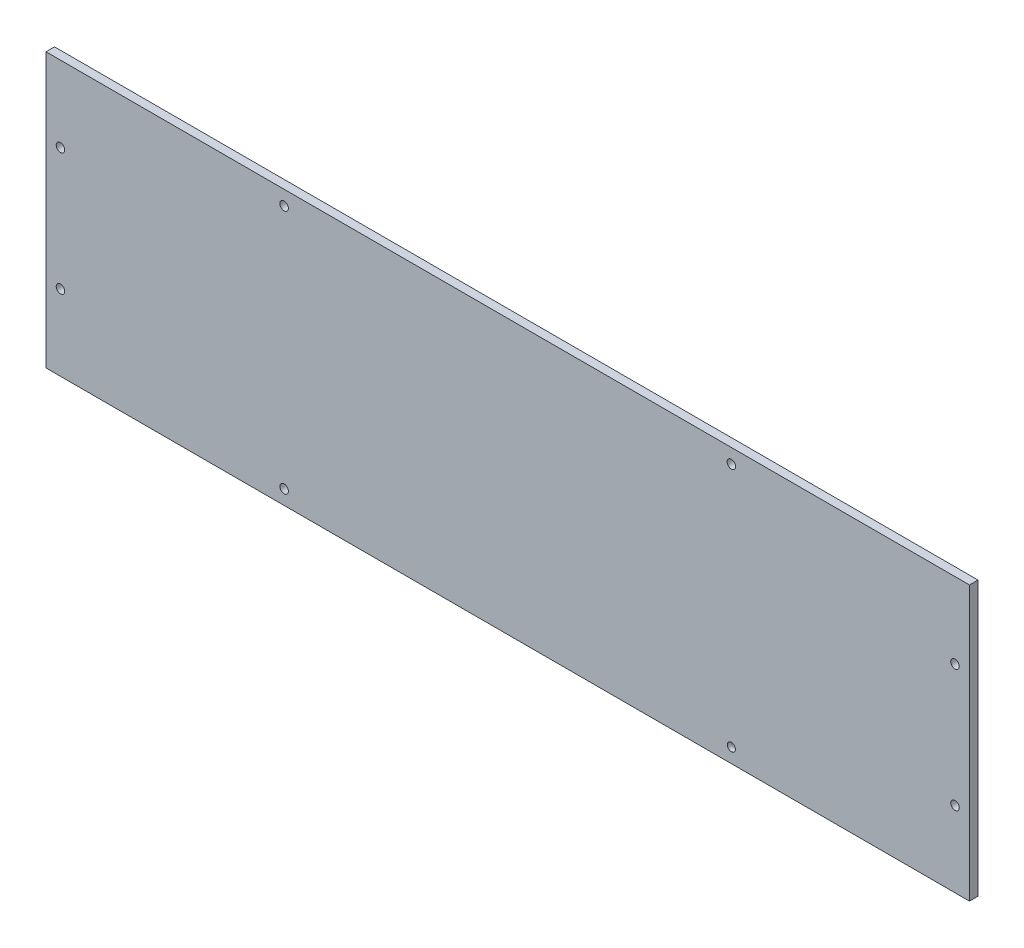
from build123d import *

# Parameters (mm, degrees)
MODEL_W             = 304.8012934
MODEL_H             = 76.2008736
MODEL_W_2           = 13.9995
MODEL_H_2           = 13.9995
MODEL_W_3           = 13.9994
MODEL_W_4           = 13.9992
MODEL_W_5           = 3.302
MODEL_H_3           = 14.2007
MODEL_W_6           = 13.999
MODEL_W_7           = 3.3
MODEL_W_8           = 3.3004
MODEL_H_4           = 14.2005
MODEL_W_9           = 14.0008
MODEL_W_10          = 3.2992
MODEL_W_11          = 13.9991
MODEL_W_12          = 14.001
MODEL_H_5           = 13.9996
BOSS_EXTRUDE2_DEPTH = 1.5
SKETCH3_W           = 324.9887066
SKETCH3_H           = 96.3745066
SKETCH3_W_2         = 304.8012934
SKETCH3_H_2         = 76.2008736
BOSS_EXTRUDE4_DEPTH = 1.5
SKETCH4_R           = 1.5
CUT_EXTRUDE2_DEPTH  = 2.54
BOSS_EXTRUDE5_DEPTH = 1.5
SKETCH6_W           = 324.9887066
SKETCH6_H           = 96.3745066
SKETCH6_R           = 1.5
SKETCH6_R_2         = 1.437968672
BOSS_EXTRUDE6_DEPTH = 1.5


with BuildPart() as part:
    # Model → Boss-Extrude2 (new body)
    with BuildSketch(Plane.XY):
        with Locations((162.4943533, 48.1803632)):
            Rectangle(MODEL_W, MODEL_H)
        with Locations((19.61845, 19.60605)):
            Rectangle(MODEL_W_2, MODEL_H_2, mode=Mode.SUBTRACT)
        with Locations((38.6684, 19.60605)):
            Rectangle(MODEL_W_3, MODEL_H_2, mode=Mode.SUBTRACT)
        with Locations((57.7185, 19.60605)):
            Rectangle(MODEL_W_4, MODEL_H_2, mode=Mode.SUBTRACT)
        with Locations((76.7685, 19.60605)):
            Rectangle(MODEL_W_4, MODEL_H_2, mode=Mode.SUBTRACT)
        with Locations((131.543, 18.95565)):
            Rectangle(MODEL_W_5, MODEL_H_3, mode=Mode.SUBTRACT)
        with Locations((143.4435, 19.60605)):
            Rectangle(MODEL_W_6, MODEL_H_2, mode=Mode.SUBTRACT)
        with Locations((155.344, 18.95565)):
            Rectangle(MODEL_W_7, MODEL_H_3, mode=Mode.SUBTRACT)
        with Locations((17.2427, 38.00555)):
            Rectangle(MODEL_W_8, MODEL_H_4, mode=Mode.SUBTRACT)
        with Locations((29.1427, 38.65605)):
            Rectangle(MODEL_W_9, MODEL_H_2, mode=Mode.SUBTRACT)
        with Locations((41.0436, 38.00555)):
            Rectangle(MODEL_W_10, MODEL_H_4, mode=Mode.SUBTRACT)
        with Locations((57.7185, 38.65605)):
            Rectangle(MODEL_W_4, MODEL_H_2, mode=Mode.SUBTRACT)
        with Locations((76.7685, 38.65605)):
            Rectangle(MODEL_W_4, MODEL_H_2, mode=Mode.SUBTRACT)
        with Locations((95.81845, 38.65605)):
            Rectangle(MODEL_W_11, MODEL_H_2, mode=Mode.SUBTRACT)
        with Locations((114.8675, 38.65605)):
            Rectangle(MODEL_W_12, MODEL_H_2, mode=Mode.SUBTRACT)
        with Locations((133.9185, 38.65605)):
            Rectangle(MODEL_W_6, MODEL_H_2, mode=Mode.SUBTRACT)
        with Locations((152.9685, 38.65605)):
            Rectangle(MODEL_W_6, MODEL_H_2, mode=Mode.SUBTRACT)
        with Locations((169.643, 18.95565)):
            Rectangle(MODEL_W_5, MODEL_H_3, mode=Mode.SUBTRACT)
        with Locations((181.5435, 19.60605)):
            Rectangle(MODEL_W_6, MODEL_H_2, mode=Mode.SUBTRACT)
        with Locations((193.444, 18.95565)):
            Rectangle(MODEL_W_7, MODEL_H_3, mode=Mode.SUBTRACT)
        with Locations((248.2185, 19.60605)):
            Rectangle(MODEL_W_6, MODEL_H_2, mode=Mode.SUBTRACT)
        with Locations((267.2685, 19.60605)):
            Rectangle(MODEL_W_6, MODEL_H_2, mode=Mode.SUBTRACT)
        with Locations((286.3185, 19.60605)):
            Rectangle(MODEL_W_6, MODEL_H_2, mode=Mode.SUBTRACT)
        with Locations((305.3685, 19.60605)):
            Rectangle(MODEL_W_6, MODEL_H_2, mode=Mode.SUBTRACT)
        with Locations((172.0185, 38.65605)):
            Rectangle(MODEL_W_6, MODEL_H_2, mode=Mode.SUBTRACT)
        with Locations((191.0685, 38.65605)):
            Rectangle(MODEL_W_6, MODEL_H_2, mode=Mode.SUBTRACT)
        with Locations((210.1185, 38.65605)):
            Rectangle(MODEL_W_6, MODEL_H_2, mode=Mode.SUBTRACT)
        with Locations((229.1685, 38.65605)):
            Rectangle(MODEL_W_6, MODEL_H_2, mode=Mode.SUBTRACT)
        with Locations((248.2185, 38.65605)):
            Rectangle(MODEL_W_6, MODEL_H_2, mode=Mode.SUBTRACT)
        with Locations((267.2685, 38.65605)):
            Rectangle(MODEL_W_6, MODEL_H_2, mode=Mode.SUBTRACT)
        with Locations((283.944, 38.00555)):
            Rectangle(MODEL_W_7, MODEL_H_4, mode=Mode.SUBTRACT)
        with Locations((295.8435, 38.65605)):
            Rectangle(MODEL_W_6, MODEL_H_2, mode=Mode.SUBTRACT)
        with Locations((307.744, 38.00555)):
            Rectangle(MODEL_W_7, MODEL_H_4, mode=Mode.SUBTRACT)
        with Locations((19.61845, 57.706)):
            Rectangle(MODEL_W_2, MODEL_H_5, mode=Mode.SUBTRACT)
        with Locations((38.6684, 57.706)):
            Rectangle(MODEL_W_3, MODEL_H_5, mode=Mode.SUBTRACT)
        with Locations((57.7185, 57.706)):
            Rectangle(MODEL_W_4, MODEL_H_5, mode=Mode.SUBTRACT)
        with Locations((76.7685, 57.706)):
            Rectangle(MODEL_W_4, MODEL_H_5, mode=Mode.SUBTRACT)
        with Locations((95.81845, 57.706)):
            Rectangle(MODEL_W_11, MODEL_H_5, mode=Mode.SUBTRACT)
        with Locations((114.8675, 57.706)):
            Rectangle(MODEL_W_12, MODEL_H_5, mode=Mode.SUBTRACT)
        with Locations((133.9185, 57.706)):
            Rectangle(MODEL_W_6, MODEL_H_5, mode=Mode.SUBTRACT)
        with Locations((152.9685, 57.706)):
            Rectangle(MODEL_W_6, MODEL_H_5, mode=Mode.SUBTRACT)
        with Locations((17.2427, 76.10545)):
            Rectangle(MODEL_W_8, MODEL_H_3, mode=Mode.SUBTRACT)
        with Locations((29.1427, 76.756)):
            Rectangle(MODEL_W_9, MODEL_H_5, mode=Mode.SUBTRACT)
        with Locations((41.0436, 76.10545)):
            Rectangle(MODEL_W_10, MODEL_H_3, mode=Mode.SUBTRACT)
        with Locations((57.7185, 76.756)):
            Rectangle(MODEL_W_4, MODEL_H_5, mode=Mode.SUBTRACT)
        with Locations((76.7685, 76.756)):
            Rectangle(MODEL_W_4, MODEL_H_5, mode=Mode.SUBTRACT)
        with Locations((95.81845, 76.756)):
            Rectangle(MODEL_W_11, MODEL_H_5, mode=Mode.SUBTRACT)
        with Locations((114.8675, 76.756)):
            Rectangle(MODEL_W_12, MODEL_H_5, mode=Mode.SUBTRACT)
        with Locations((133.9185, 76.756)):
            Rectangle(MODEL_W_6, MODEL_H_5, mode=Mode.SUBTRACT)
        with Locations((152.9685, 76.756)):
            Rectangle(MODEL_W_6, MODEL_H_5, mode=Mode.SUBTRACT)
        with Locations((172.0185, 57.706)):
            Rectangle(MODEL_W_6, MODEL_H_5, mode=Mode.SUBTRACT)
        with Locations((191.0685, 57.706)):
            Rectangle(MODEL_W_6, MODEL_H_5, mode=Mode.SUBTRACT)
        with Locations((210.1185, 57.706)):
            Rectangle(MODEL_W_6, MODEL_H_5, mode=Mode.SUBTRACT)
        with Locations((229.1685, 57.706)):
            Rectangle(MODEL_W_6, MODEL_H_5, mode=Mode.SUBTRACT)
        with Locations((248.2185, 57.706)):
            Rectangle(MODEL_W_6, MODEL_H_5, mode=Mode.SUBTRACT)
        with Locations((267.2685, 57.706)):
            Rectangle(MODEL_W_6, MODEL_H_5, mode=Mode.SUBTRACT)
        with Locations((286.3185, 57.706)):
            Rectangle(MODEL_W_6, MODEL_H_5, mode=Mode.SUBTRACT)
        with Locations((305.3685, 57.706)):
            Rectangle(MODEL_W_6, MODEL_H_5, mode=Mode.SUBTRACT)
        with Locations((172.0185, 76.756)):
            Rectangle(MODEL_W_6, MODEL_H_5, mode=Mode.SUBTRACT)
        with Locations((191.0685, 76.756)):
            Rectangle(MODEL_W_6, MODEL_H_5, mode=Mode.SUBTRACT)
        with Locations((210.1185, 76.756)):
            Rectangle(MODEL_W_6, MODEL_H_5, mode=Mode.SUBTRACT)
        with Locations((229.1685, 76.756)):
            Rectangle(MODEL_W_6, MODEL_H_5, mode=Mode.SUBTRACT)
        with Locations((248.2185, 76.756)):
            Rectangle(MODEL_W_6, MODEL_H_5, mode=Mode.SUBTRACT)
        with Locations((267.2685, 76.756)):
            Rectangle(MODEL_W_6, MODEL_H_5, mode=Mode.SUBTRACT)
        with Locations((283.944, 76.10545)):
            Rectangle(MODEL_W_7, MODEL_H_3, mode=Mode.SUBTRACT)
        with Locations((295.8435, 76.756)):
            Rectangle(MODEL_W_6, MODEL_H_5, mode=Mode.SUBTRACT)
        with Locations((307.744, 76.10545)):
            Rectangle(MODEL_W_7, MODEL_H_3, mode=Mode.SUBTRACT)
    extrude(amount=BOSS_EXTRUDE2_DEPTH)

    # Sketch3 → Boss-Extrude4 (add)
    with BuildSketch(Plane.XY.offset(1.5)):
        with Locations((162.4943533, 48.1872533)):
            Rectangle(SKETCH3_W, SKETCH3_H)
        with Locations((162.4943533, 48.1803632)):
            Rectangle(SKETCH3_W_2, SKETCH3_H_2, mode=Mode.SUBTRACT)
    extrude(amount=-BOSS_EXTRUDE4_DEPTH)

    # Sketch4 → Cut-Extrude2 (cut)
    with BuildSketch(Plane.XY):
        with Locations((5.0937066, 69.7305816)):
            Circle(SKETCH4_R)
        with Locations((5.0937066, 26.6301448)):
            Circle(SKETCH4_R)
        with Locations((83.79402995, 5.0799264)):
            Circle(SKETCH4_R)
        with Locations((241.19467665, 5.0799264)):
            Circle(SKETCH4_R)
        with Locations((319.895, 26.6301448)):
            Circle(SKETCH4_R)
        with Locations((319.895, 69.7305816)):
            Circle(SKETCH4_R)
        with Locations((241.19467665, 91.2808)):
            Circle(SKETCH4_R)
        with Locations((83.79402995, 91.2808)):
            Circle(SKETCH4_R)
    extrude(amount=CUT_EXTRUDE2_DEPTH, mode=Mode.SUBTRACT)

    # Sketch5 → Boss-Extrude5 (add)
    with BuildSketch(Plane.XY.offset(1.5)):
        Polygon((114.22283219, 12.6063), (12.6187, 12.6063), (12.6187, 64.7058), (12.6187, 85.328205222), (312.368, 85.328205222), (312.368, 64.7058), (312.368, 12.6063), (207.016630052, 12.6063), (207.016630052, 7.29705702), (114.22283219, 7.29705702), align=None)
    extrude(amount=-BOSS_EXTRUDE5_DEPTH)

    # Sketch6 → Boss-Extrude6 (add)
    with BuildSketch(Plane.XY.offset(1.5)):
        with Locations((162.4943533, 48.1872533)):
            Rectangle(SKETCH6_W, SKETCH6_H)
        with Locations((319.895, 69.7305816)):
            Circle(SKETCH6_R, mode=Mode.SUBTRACT)
        with Locations((319.895, 26.6301448)):
            Circle(SKETCH6_R, mode=Mode.SUBTRACT)
        with Locations((241.19467665, 5.0799264)):
            Circle(SKETCH6_R_2, mode=Mode.SUBTRACT)
        with Locations((241.19467665, 91.2808)):
            Circle(SKETCH6_R, mode=Mode.SUBTRACT)
        with Locations((5.0937066, 26.6301448)):
            Circle(SKETCH6_R, mode=Mode.SUBTRACT)
        with Locations((83.79402995, 5.0799264)):
            Circle(SKETCH6_R, mode=Mode.SUBTRACT)
        with Locations((83.79402995, 91.2808)):
            Circle(SKETCH6_R, mode=Mode.SUBTRACT)
        with Locations((5.0937066, 69.7305816)):
            Circle(SKETCH6_R, mode=Mode.SUBTRACT)
    extrude(amount=BOSS_EXTRUDE6_DEPTH)


solid = part.part
